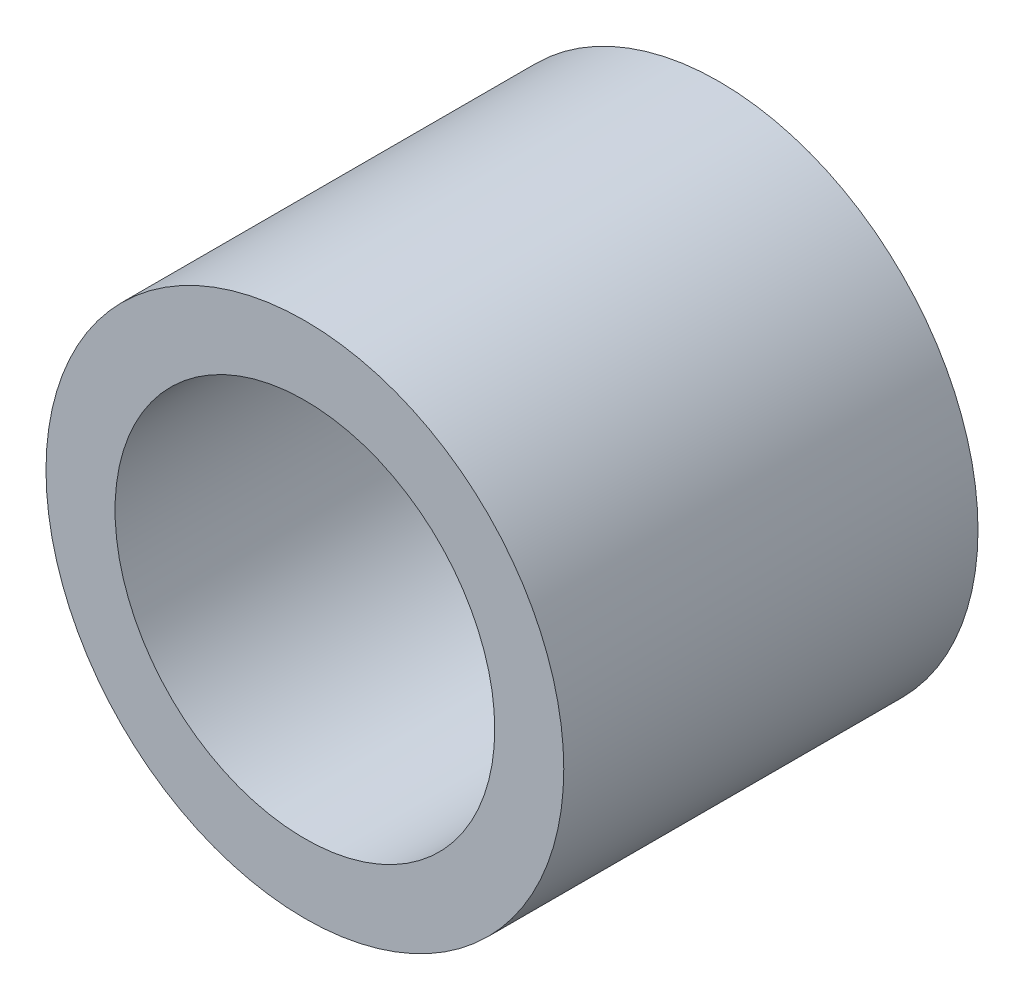
from build123d import *

# Parameters (mm, degrees)
SKETCH1_R           = 3.75
SKETCH1_R_2         = 2.75
BOSS_EXTRUDE1_DEPTH = 6


with BuildPart() as part:
    # Sketch1 → Boss-Extrude1 (new body)
    with BuildSketch(Plane.XY):
        Circle(SKETCH1_R)
        Circle(SKETCH1_R_2, mode=Mode.SUBTRACT)
    extrude(amount=BOSS_EXTRUDE1_DEPTH)


solid = part.part
